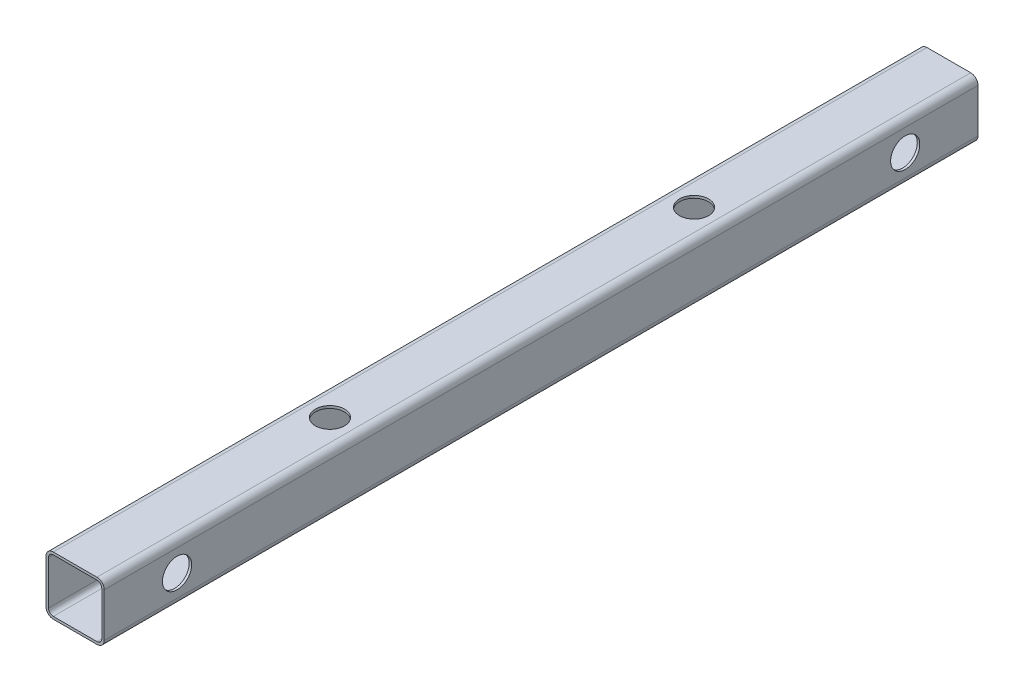
from build123d import *

# Parameters (mm, degrees)
BOSS_EXTRUDE1_DEPTH      = 120
BOSS_EXTRUDE1_DEPTH_BACK = 120
CUT_EXTRUDE1_START       = -17
SKETCH2_R                = 4
CUT_EXTRUDE1_DEPTH       = 18
SKETCH3_R                = 4
CUT_EXTRUDE2_DEPTH       = 1
CUT_EXTRUDE2_DEPTH_BACK  = 17


with BuildPart() as part:
    # Sketch1 → Boss-Extrude1 (new body, two sides)
    with BuildSketch(Plane.XY) as boss_extrude1_sk:
        with BuildLine():
            Line((-6, -8), (6, -8))
            ThreePointArc((6, -8), (7.414213562, -7.414213562), (8, -6))
            Line((8, -6), (8, 6))
            ThreePointArc((8, 6), (7.414213562, 7.414213562), (6, 8))
            Line((6, 8), (-6, 8))
            ThreePointArc((-6, 8), (-7.414213562, 7.414213562), (-8, 6))
            Line((-8, 6), (-8, -6))
            ThreePointArc((-8, -6), (-7.414213562, -7.414213562), (-6, -8))
        make_face()
        with BuildLine():
            Line((-6, 7.32), (6, 7.32))
            ThreePointArc((6, 7.32), (6.933380951, 6.933380951), (7.32, 6))
            Line((7.32, 6), (7.32, -6))
            ThreePointArc((7.32, -6), (6.933380951, -6.933380951), (6, -7.32))
            Line((6, -7.32), (-6, -7.32))
            ThreePointArc((-6, -7.32), (-6.933380951, -6.933380951), (-7.32, -6))
            Line((-7.32, -6), (-7.32, 6))
            ThreePointArc((-7.32, 6), (-6.933380951, 6.933380951), (-6, 7.32))
        make_face(mode=Mode.SUBTRACT)
    extrude(amount=BOSS_EXTRUDE1_DEPTH)
    extrude(boss_extrude1_sk.sketch, amount=-BOSS_EXTRUDE1_DEPTH_BACK)

    # Sketch2 → Cut-Extrude1 (cut)
    with BuildSketch(Plane(origin=(0, 8, 0), x_dir=(1, 0, 0), z_dir=(0, 1, 0)).offset(CUT_EXTRUDE1_START)):
        with Locations((0, -50)):
            Circle(SKETCH2_R)
    cut_extrude1 = extrude(amount=CUT_EXTRUDE1_DEPTH, mode=Mode.SUBTRACT)

    # Mirror1: Cut-Extrude1 across plane
    add(cut_extrude1.mirror(Plane.XY), mode=Mode.SUBTRACT)

    # Sketch3 → Cut-Extrude2 (cut, two sides)
    with BuildSketch(Plane(origin=(8, 0, 0), x_dir=(0, 0, -1), z_dir=(1, 0, 0))) as cut_extrude2_sk:
        with Locations((-100, 0)):
            Circle(SKETCH3_R)
        with Locations((100, 0)):
            Circle(SKETCH3_R)
    extrude(amount=CUT_EXTRUDE2_DEPTH, mode=Mode.SUBTRACT)
    extrude(cut_extrude2_sk.sketch, amount=-CUT_EXTRUDE2_DEPTH_BACK, mode=Mode.SUBTRACT)


solid = part.part
